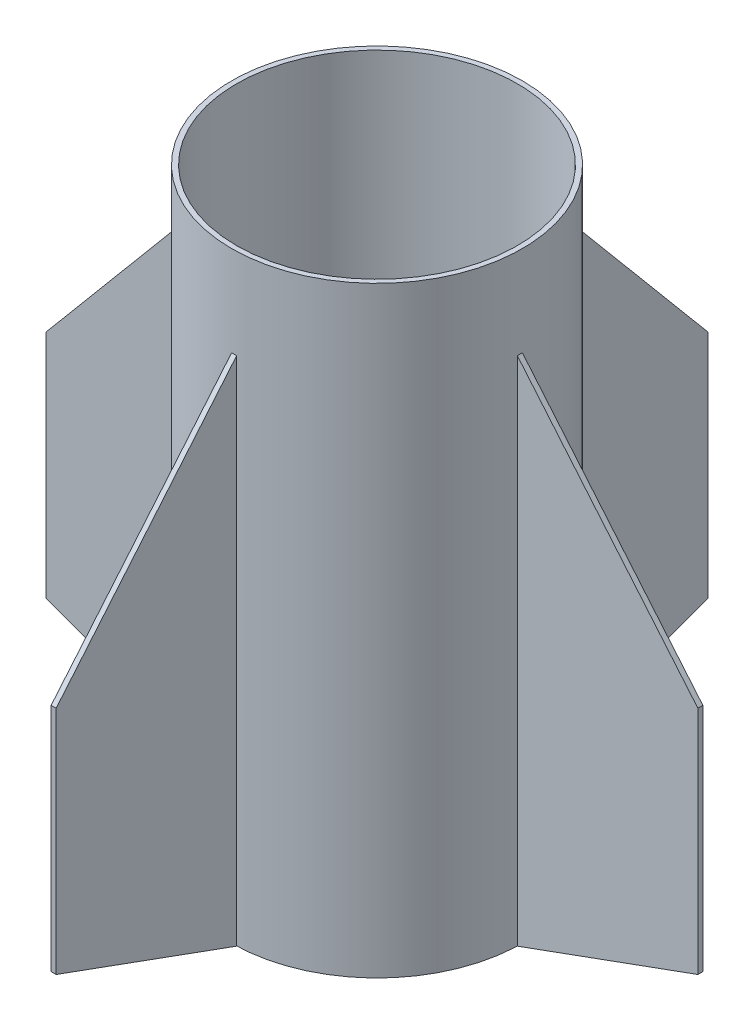
from build123d import *

# Parameters (mm, degrees)
SKETCH1_R           = 92.075
SKETCH1_R_2         = 88.9
BOSS_EXTRUDE1_DEPTH = 381
BOSS_EXTRUDE2_DEPTH = 3.175
BOSS_EXTRUDE3_DEPTH = 3.175
BOSS_EXTRUDE4_DEPTH = 3.175
BOSS_EXTRUDE5_DEPTH = 3.175


with BuildPart() as part:
    # Sketch1 → Boss-Extrude1 (new body)
    with BuildSketch(Plane(origin=(0, 0, 0), x_dir=(1, 0, 0), z_dir=(0, 1, 0))):
        Circle(SKETCH1_R)
        Circle(SKETCH1_R_2, mode=Mode.SUBTRACT)
    extrude(amount=BOSS_EXTRUDE1_DEPTH)


with BuildPart() as body_2:
    # Sketch2 → Boss-Extrude2 (new body)
    with BuildSketch(Plane(origin=(0, 0, 0), x_dir=(0, 0, -1), z_dir=(1, 0, 0))):
        Polygon((-92.075, 323.85), (-206.375, 187.657672757), (-206.375, 41.607672757), (-92.075, 0), align=None)
    extrude(amount=BOSS_EXTRUDE2_DEPTH)


with BuildPart() as body_3:
    # Sketch5 → Boss-Extrude3 (new body)
    with BuildSketch(Plane(origin=(0, 0, 0), x_dir=(0, 0, -1), z_dir=(1, 0, 0))):
        Polygon((92.075, 323.85), (206.375, 187.657672757), (206.375, 41.607672757), (92.075, 0), align=None)
    extrude(amount=BOSS_EXTRUDE3_DEPTH)


with BuildPart() as body_4:
    # Sketch6 → Boss-Extrude4 (new body)
    with BuildSketch(Plane.XY):
        Polygon((-92.075, 323.85), (-206.375, 187.657672757), (-206.375, 41.607672757), (-92.075, 0), align=None)
    extrude(amount=BOSS_EXTRUDE4_DEPTH)


with BuildPart() as body_5:
    # Sketch7 → Boss-Extrude5 (new body)
    with BuildSketch(Plane.XY):
        Polygon((92.075, 323.85), (206.375, 187.657672757), (206.375, 41.607672757), (92.075, 0), align=None)
    extrude(amount=BOSS_EXTRUDE5_DEPTH)


solid = Compound([part.part, body_2.part, body_3.part, body_4.part, body_5.part])
